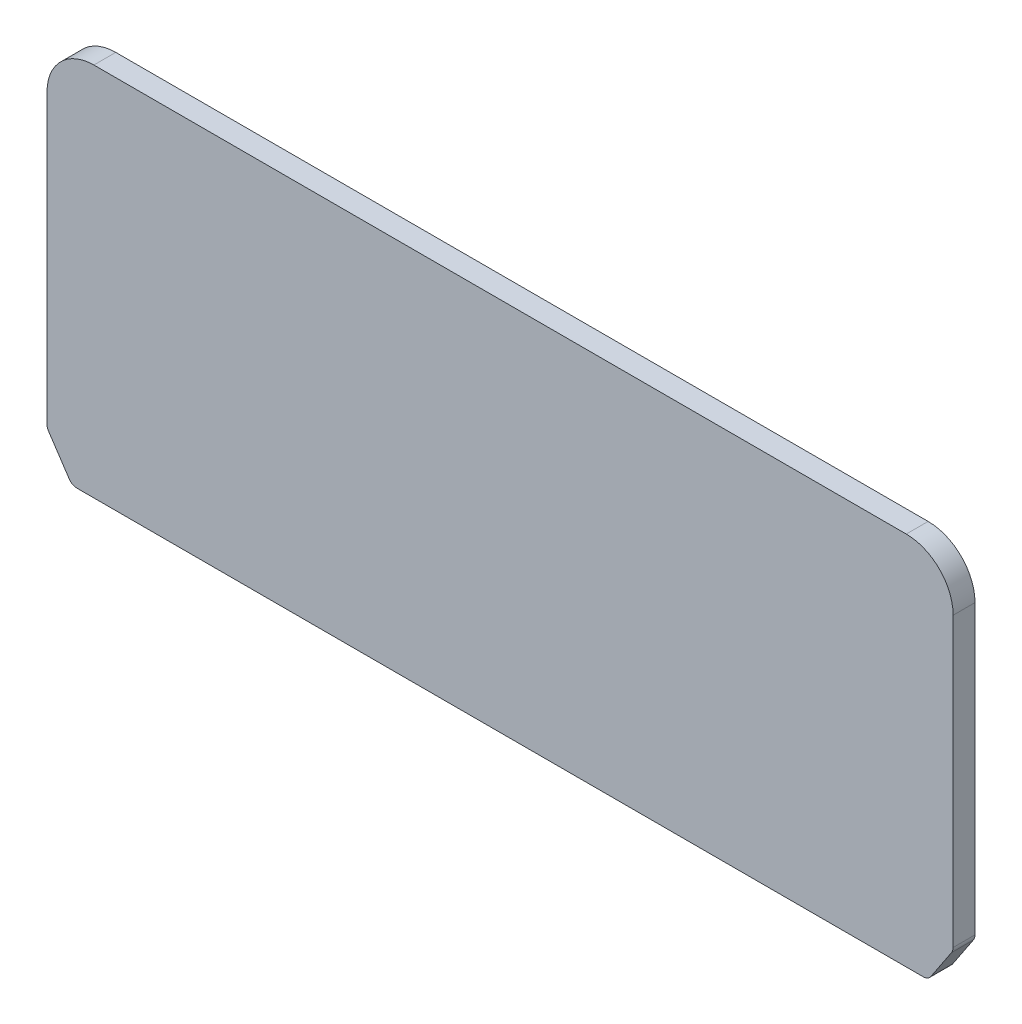
from build123d import *

# Parameters (mm, degrees)
EXTRUDE1_DEPTH = 7


with BuildPart() as part:
    # Sketch1 → Extrude1 (new body)
    with BuildSketch(Plane.XY):
        with BuildLine():
            Line((-144.496150883, 11.244226325), (-137.890599608, 1.335899411))
            ThreePointArc((-137.890599608, 1.335899411), (-136.810022501, 0.354976204), (-135.394448725, 0))
            Line((-135.394448725, 0), (135.394448725, 0))
            ThreePointArc((135.394448725, 0), (136.810022501, 0.354976204), (137.890599608, 1.335899411))
            Line((137.890599608, 1.335899411), (144.496150883, 11.244226325))
            ThreePointArc((144.496150883, 11.244226325), (144.871276079, 12.038974467), (145, 12.908326913))
            Line((145, 12.908326913), (145, 105))
            ThreePointArc((145, 105), (140.606601718, 115.606601718), (130, 120))
            Line((130, 120), (-130, 120))
            ThreePointArc((-130, 120), (-140.606601718, 115.606601718), (-145, 105))
            Line((-145, 105), (-145, 12.908326913))
            ThreePointArc((-145, 12.908326913), (-144.871276079, 12.038974467), (-144.496150883, 11.244226325))
        make_face()
    extrude(amount=EXTRUDE1_DEPTH)


solid = part.part
